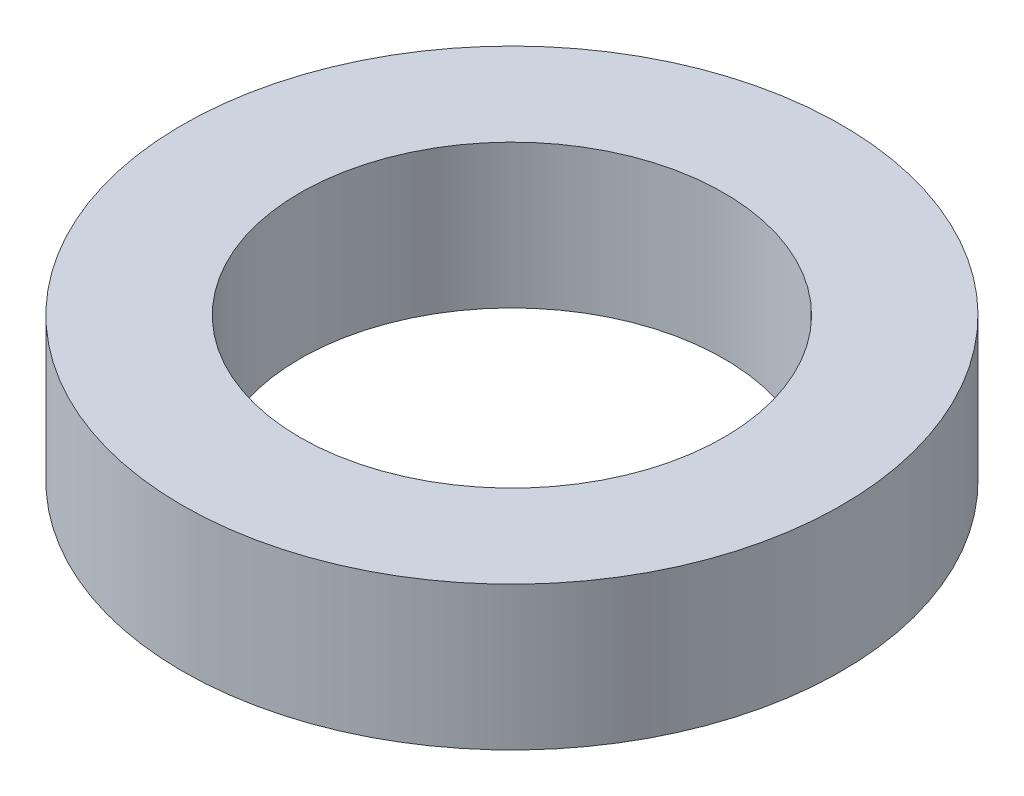
from build123d import *

# Parameters (mm, degrees)
SKETCH1_R           = 28
BOSS_EXTRUDE1_DEPTH = 12.2
SKETCH2_R           = 18.0025
CUT_EXTRUDE1_DEPTH  = 13.2


with BuildPart() as part:
    # Sketch1 → Boss-Extrude1 (new body)
    with BuildSketch(Plane(origin=(0, 0, 0), x_dir=(1, 0, 0), z_dir=(0, 1, 0))):
        Circle(SKETCH1_R)
    extrude(amount=BOSS_EXTRUDE1_DEPTH)

    # Sketch2 → Cut-Extrude1 (cut, through all)
    with BuildSketch(Plane(origin=(0, 0, 0), x_dir=(1, 0, 0), z_dir=(0, 1, 0))):
        Circle(SKETCH2_R)
    extrude(amount=CUT_EXTRUDE1_DEPTH, mode=Mode.SUBTRACT)


solid = part.part
